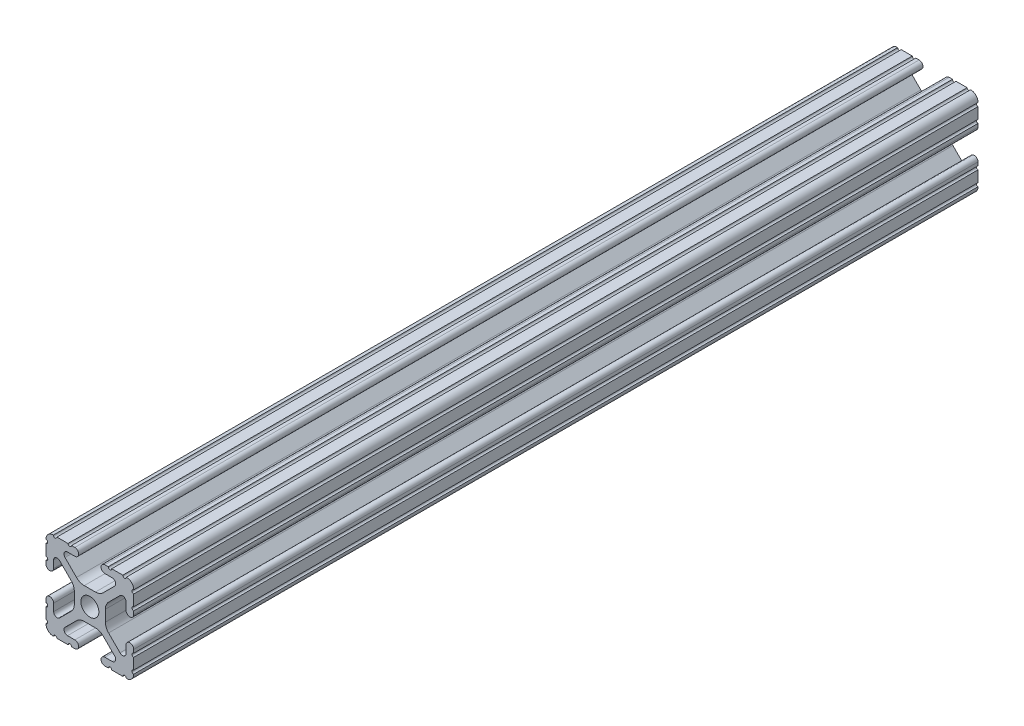
from build123d import *

# Parameters (mm, degrees)
SKETCH1_R           = 2.6035
BOSS_EXTRUDE1_DEPTH = 122.2756


with BuildPart() as part:
    # Sketch1 → Boss-Extrude1 (new body, symmetric)
    with BuildSketch(Plane(origin=(0, 0, -450.85), x_dir=(-1, 0, 0), z_dir=(0, 0, -1))):
        with BuildLine():
            Line((12.7, -9.5504), (12.7, -6.3330836))
            ThreePointArc((12.7, -6.3330836), (12.192, -5.8250836), (12.7, -5.3170836))
            Line((12.7, -5.3170836), (12.7, -4.3434))
            ThreePointArc((12.7, -4.3434), (11.5951, -3.2385), (10.4902, -4.3434))
            Line((10.4902, -4.3434), (10.4902, -6.474794456))
            ThreePointArc((10.4902, -6.474794456), (9.863006367, -7.413456061), (8.75577951, -7.193214945))
            Line((8.75577951, -7.193214945), (5.42573597, -3.863171405))
            ThreePointArc((5.42573597, -3.863171405), (4.737482484, -2.833127272), (4.4958, -1.618107374))
            Line((4.4958, -1.618107374), (4.4958, 1.618107374))
            ThreePointArc((4.4958, 1.618107374), (4.737482484, 2.833127272), (5.42573597, 3.863171405))
            Line((5.42573597, 3.863171405), (8.75577951, 7.193214945))
            ThreePointArc((8.75577951, 7.193214945), (9.863006367, 7.413456061), (10.4902, 6.474794456))
            Line((10.4902, 6.474794456), (10.4902, 4.343399971))
            ThreePointArc((10.4902, 4.343399971), (11.5951, 3.238499971), (12.7, 4.343399971))
            Line((12.7, 4.343399971), (12.7, 5.3170836))
            ThreePointArc((12.7, 5.3170836), (12.192, 5.8250836), (12.7, 6.3330836))
            Line((12.7, 6.3330836), (12.7, 9.5504))
            ThreePointArc((12.7, 9.5504), (12.192000006, 10.058323491), (12.699846982, 10.566399977))
            ThreePointArc((12.699846982, 10.566399977), (12.082522516, 12.082522516), (10.566399977, 12.699846982))
            ThreePointArc((10.566399977, 12.699846982), (10.058323491, 12.192000006), (9.5504, 12.7))
            Line((9.5504, 12.7), (6.3330836, 12.7))
            ThreePointArc((6.3330836, 12.7), (5.8250836, 12.192), (5.3170836, 12.7))
            Line((5.3170836, 12.7), (4.3434, 12.7))
            ThreePointArc((4.3434, 12.7), (3.2385, 11.5951), (4.3434, 10.4902))
            Line((4.3434, 10.4902), (6.474794456, 10.4902))
            ThreePointArc((6.474794456, 10.4902), (7.413456061, 9.863006367), (7.193214945, 8.75577951))
            Line((7.193214945, 8.75577951), (3.863171405, 5.42573597))
            ThreePointArc((3.863171405, 5.42573597), (2.833127272, 4.737482484), (1.618107374, 4.4958))
            Line((1.618107374, 4.4958), (-1.618107374, 4.4958))
            ThreePointArc((-1.618107374, 4.4958), (-2.833127272, 4.737482484), (-3.863171405, 5.42573597))
            Line((-3.863171405, 5.42573597), (-7.193214945, 8.75577951))
            ThreePointArc((-7.193214945, 8.75577951), (-7.413456061, 9.863006367), (-6.474794456, 10.4902))
            Line((-6.474794456, 10.4902), (-4.343399971, 10.4902))
            ThreePointArc((-4.343399971, 10.4902), (-3.238499971, 11.5951), (-4.343399971, 12.7))
            Line((-4.343399971, 12.7), (-5.3170836, 12.7))
            ThreePointArc((-5.3170836, 12.7), (-5.8250836, 12.192), (-6.3330836, 12.7))
            Line((-6.3330836, 12.7), (-9.5504, 12.7))
            ThreePointArc((-9.5504, 12.7), (-10.058323491, 12.192000006), (-10.566399977, 12.699846982))
            ThreePointArc((-10.566399977, 12.699846982), (-12.082522516, 12.082522516), (-12.699846982, 10.566399977))
            ThreePointArc((-12.699846982, 10.566399977), (-12.192000006, 10.058323491), (-12.7, 9.5504))
            Line((-12.7, 9.5504), (-12.7, 6.3330836))
            ThreePointArc((-12.7, 6.3330836), (-12.192, 5.8250836), (-12.7, 5.3170836))
            Line((-12.7, 5.3170836), (-12.7, 4.3434))
            ThreePointArc((-12.7, 4.3434), (-11.5951, 3.2385), (-10.4902, 4.3434))
            Line((-10.4902, 4.3434), (-10.4902, 6.474794456))
            ThreePointArc((-10.4902, 6.474794456), (-9.863006367, 7.413456061), (-8.75577951, 7.193214945))
            Line((-8.75577951, 7.193214945), (-5.42573597, 3.863171405))
            ThreePointArc((-5.42573597, 3.863171405), (-4.737482484, 2.833127272), (-4.4958, 1.618107374))
            Line((-4.4958, 1.618107374), (-4.4958, -1.618107374))
            ThreePointArc((-4.4958, -1.618107374), (-4.737482484, -2.833127272), (-5.42573597, -3.863171405))
            Line((-5.42573597, -3.863171405), (-8.75577951, -7.193214945))
            ThreePointArc((-8.75577951, -7.193214945), (-9.863006367, -7.413456061), (-10.4902, -6.474794456))
            Line((-10.4902, -6.474794456), (-10.4902, -4.343399971))
            ThreePointArc((-10.4902, -4.343399971), (-11.5951, -3.238499971), (-12.7, -4.343399971))
            Line((-12.7, -4.343399971), (-12.7, -5.3170836))
            ThreePointArc((-12.7, -5.3170836), (-12.192, -5.8250836), (-12.7, -6.3330836))
            Line((-12.7, -6.3330836), (-12.7, -9.5504))
            ThreePointArc((-12.7, -9.5504), (-12.192000006, -10.058323491), (-12.699846982, -10.566399977))
            ThreePointArc((-12.699846982, -10.566399977), (-12.082522516, -12.082522516), (-10.566399977, -12.699846982))
            ThreePointArc((-10.566399977, -12.699846982), (-10.058323491, -12.192000006), (-9.5504, -12.7))
            Line((-9.5504, -12.7), (-6.3330836, -12.7))
            ThreePointArc((-6.3330836, -12.7), (-5.8250836, -12.192), (-5.3170836, -12.7))
            Line((-5.3170836, -12.7), (-4.3434, -12.7))
            ThreePointArc((-4.3434, -12.7), (-3.2385, -11.5951), (-4.3434, -10.4902))
            Line((-4.3434, -10.4902), (-6.474794456, -10.4902))
            ThreePointArc((-6.474794456, -10.4902), (-7.413456061, -9.863006367), (-7.193214945, -8.75577951))
            Line((-7.193214945, -8.75577951), (-3.863171405, -5.42573597))
            ThreePointArc((-3.863171405, -5.42573597), (-2.833127272, -4.737482484), (-1.618107374, -4.4958))
            Line((-1.618107374, -4.4958), (1.618107374, -4.4958))
            ThreePointArc((1.618107374, -4.4958), (2.833127272, -4.737482484), (3.863171405, -5.42573597))
            Line((3.863171405, -5.42573597), (7.193214945, -8.75577951))
            ThreePointArc((7.193214945, -8.75577951), (7.413456061, -9.863006367), (6.474794456, -10.4902))
            Line((6.474794456, -10.4902), (4.343399971, -10.4902))
            ThreePointArc((4.343399971, -10.4902), (3.238499971, -11.5951), (4.343399971, -12.7))
            Line((4.343399971, -12.7), (5.3170836, -12.7))
            ThreePointArc((5.3170836, -12.7), (5.8250836, -12.192), (6.3330836, -12.7))
            Line((6.3330836, -12.7), (9.5504, -12.7))
            ThreePointArc((9.5504, -12.7), (10.058323491, -12.192000006), (10.566399977, -12.699846982))
            ThreePointArc((10.566399977, -12.699846982), (12.082522516, -12.082522516), (12.699846982, -10.566399977))
            ThreePointArc((12.699846982, -10.566399977), (12.192000006, -10.058323491), (12.7, -9.5504))
        make_face()
        Circle(SKETCH1_R, mode=Mode.SUBTRACT)
    extrude(amount=BOSS_EXTRUDE1_DEPTH, both=True)


solid = part.part
